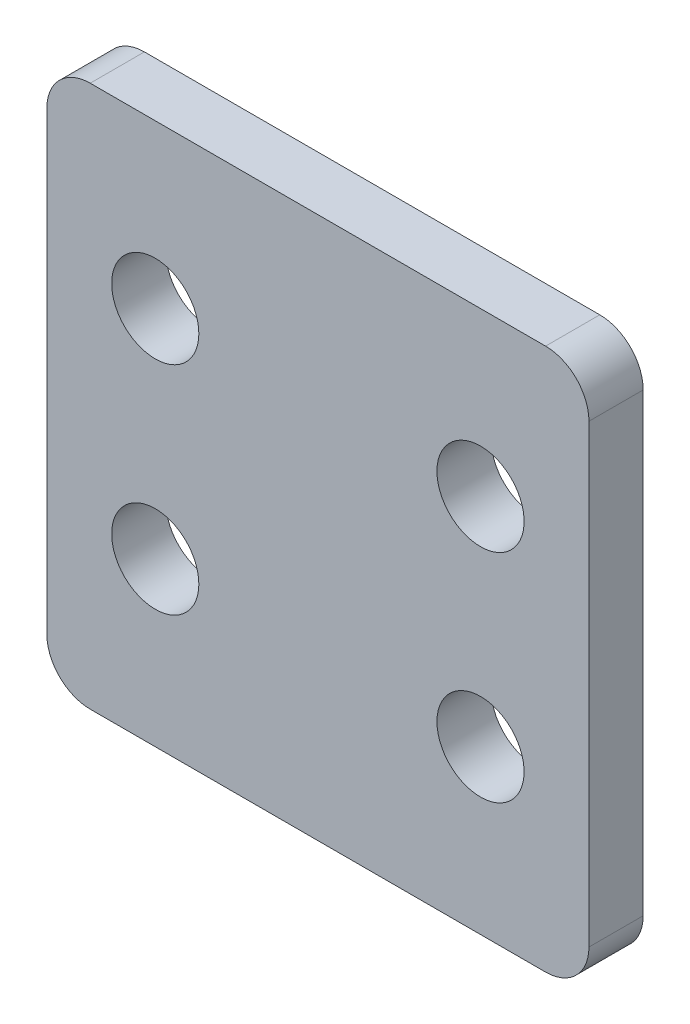
from build123d import *

# Parameters (mm, degrees)
SKETCH1_W           = 31.75
SKETCH1_H           = 31.75
SKETCH1_R           = 2.5527
BOSS_EXTRUDE1_DEPTH = 3.175
FILLET1_R           = 2.54


with BuildPart() as part:
    # Sketch1 → Boss-Extrude1 (new body)
    with BuildSketch(Plane.XY):
        Rectangle(SKETCH1_W, SKETCH1_H)
        with Locations((-9.525, -6.35)):
            Circle(SKETCH1_R, mode=Mode.SUBTRACT)
        with Locations((-9.525, 6.35)):
            Circle(SKETCH1_R, mode=Mode.SUBTRACT)
        with Locations((9.525, -6.35)):
            Circle(SKETCH1_R, mode=Mode.SUBTRACT)
        with Locations((9.525, 6.35)):
            Circle(SKETCH1_R, mode=Mode.SUBTRACT)
    extrude(amount=BOSS_EXTRUDE1_DEPTH)

    # Fillet1
    fillet1_edges = [part.edges().sort_by_distance(p)[0] for p in [
        (15.875, -15.875, 1.5875),
        (-15.875, -15.875, 1.5875),
        (-15.875, 15.875, 1.5875),
        (15.875, 15.875, 1.5875),
    ]]
    fillet(fillet1_edges, radius=FILLET1_R)


solid = part.part
